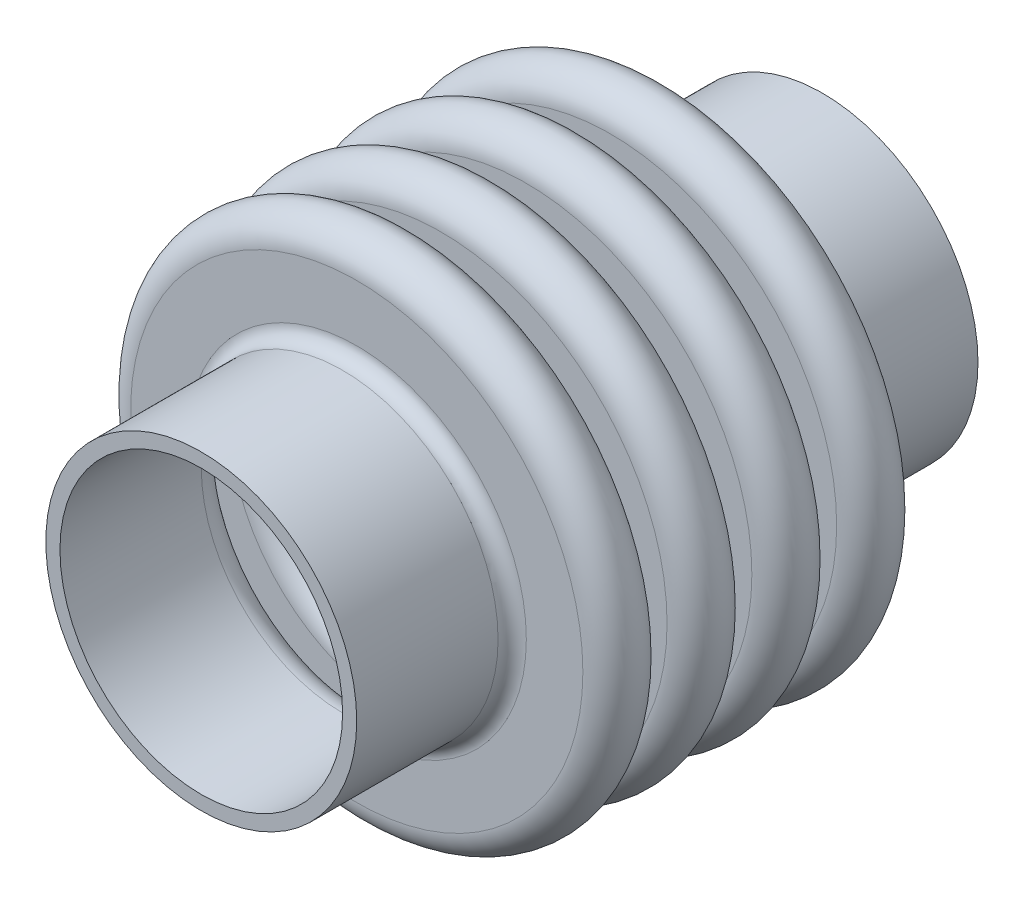
from build123d import *


with BuildPart() as part:
    # Sketch1 → Revolve1 (revolve)
    with BuildSketch(Plane(origin=(0, 0, 0), x_dir=(0, 0, -1), z_dir=(1, 0, 0))):
        with BuildLine():
            Line((-43.18, 27.94), (-17.78, 27.94))
            ThreePointArc((-17.78, 27.94), (-15.983948776, 28.683948776), (-15.24, 30.48))
            Line((-15.24, 30.48), (-15.24, 40.64))
            ThreePointArc((-15.24, 40.64), (-10.16, 45.72), (-5.08, 40.64))
            Line((-5.08, 40.64), (-5.08, 30.48))
            ThreePointArc((-5.08, 30.48), (-2.594488225, 27.994488225), (-0.108976449, 30.48))
            Line((-0.108976449, 30.48), (-0.108976449, 40.64))
            ThreePointArc((-0.108976449, 40.64), (4.971023551, 45.72), (10.051023551, 40.64))
            Line((10.051023551, 40.64), (10.051023551, 30.48))
            ThreePointArc((10.051023551, 30.48), (12.591023551, 27.94), (15.131023551, 30.48))
            Line((15.131023551, 30.48), (15.131023551, 40.64))
            ThreePointArc((15.131023551, 40.64), (20.211023551, 45.72), (25.291023551, 40.64))
            Line((25.291023551, 40.64), (25.291023551, 30.48))
            ThreePointArc((25.291023551, 30.48), (27.831023551, 27.94), (30.371023551, 30.48))
            Line((30.371023551, 30.48), (30.371023551, 40.64))
            ThreePointArc((30.371023551, 40.64), (35.451023551, 45.72), (40.531023551, 40.64))
            Line((40.531023551, 40.64), (40.531023551, 30.48))
            ThreePointArc((40.531023551, 30.48), (41.274972327, 28.683948776), (43.071023551, 27.94))
            Line((43.071023551, 27.94), (68.471023551, 27.94))
            Line((68.471023551, 27.94), (68.471023551, 25.4))
            Line((68.471023551, 25.4), (43.071023551, 25.4))
            ThreePointArc((43.071023551, 25.4), (39.478921102, 26.887897552), (37.991023551, 30.48))
            Line((37.991023551, 30.48), (37.991023551, 40.64))
            ThreePointArc((37.991023551, 40.64), (35.451023551, 43.18), (32.911023551, 40.64))
            Line((32.911023551, 40.64), (32.911023551, 30.48))
            ThreePointArc((32.911023551, 30.48), (27.831023551, 25.4), (22.751023551, 30.48))
            Line((22.751023551, 30.48), (22.751023551, 40.64))
            ThreePointArc((22.751023551, 40.64), (20.211023551, 43.18), (17.671023551, 40.64))
            Line((17.671023551, 40.64), (17.671023551, 30.48))
            ThreePointArc((17.671023551, 30.48), (12.591023551, 25.4), (7.511023551, 30.48))
            Line((7.511023551, 30.48), (7.511023551, 40.64))
            ThreePointArc((7.511023551, 40.64), (4.971023551, 43.18), (2.431023551, 40.64))
            Line((2.431023551, 40.64), (2.431023551, 30.48))
            ThreePointArc((2.431023551, 30.48), (-2.594488225, 25.454488225), (-7.62, 30.48))
            Line((-7.62, 30.48), (-7.62, 40.64))
            ThreePointArc((-7.62, 40.64), (-10.16, 43.18), (-12.7, 40.64))
            Line((-12.7, 40.64), (-12.7, 30.48))
            ThreePointArc((-12.7, 30.48), (-14.187897552, 26.887897552), (-17.78, 25.4))
            Line((-17.78, 25.4), (-43.18, 25.4))
            Line((-43.18, 25.4), (-43.18, 27.94))
        make_face()
    revolve(axis=Axis((0, 0, 39.014914438), (0, 0, -1)))


solid = part.part
